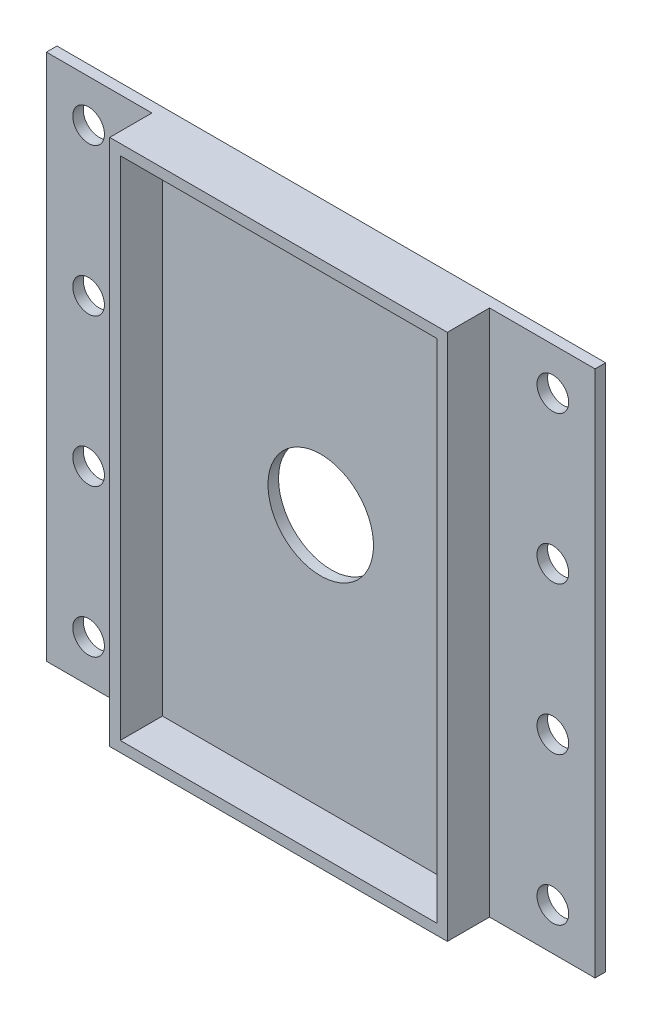
from build123d import *

# Parameters (mm, degrees)
ESQUISSE1_W             = 160
ESQUISSE1_H             = 250
ESQUISSE1_W_2           = 150
ESQUISSE1_H_2           = 240
BOSS_EXTRU_1_DEPTH      = 20
ESQUISSE2_W             = 260
ESQUISSE2_H             = 250
BOSS_EXTRU_2_DEPTH      = 5
ESQUISSE3_R             = 25
ENL_V_MAT_EXTRU_1_DEPTH = 5
ESQUISSE4_R             = 7.5
ENL_V_MAT_EXTRU_2_DEPTH = 10


with BuildPart() as part:
    # Esquisse1 → Boss.-Extru.1 (new body)
    with BuildSketch(Plane.XY):
        with Locations((-80, 125)):
            Rectangle(ESQUISSE1_W, ESQUISSE1_H)
        with Locations((-80, 125)):
            Rectangle(ESQUISSE1_W_2, ESQUISSE1_H_2, mode=Mode.SUBTRACT)
    extrude(amount=BOSS_EXTRU_1_DEPTH)

    # Esquisse2 → Boss.-Extru.2 (add)
    with BuildSketch(Plane(origin=(0, 0, 0), x_dir=(-1, 0, 0), z_dir=(0, 0, -1))):
        with Locations((80, 125)):
            Rectangle(ESQUISSE2_W, ESQUISSE2_H)
    extrude(amount=BOSS_EXTRU_2_DEPTH)

    # Esquisse3 → Enlèv. mat.-Extru.1 (cut)
    with BuildSketch(Plane(origin=(0, 0, -5), x_dir=(-1, 0, 0), z_dir=(0, 0, -1))):
        with Locations((80, 125)):
            Circle(ESQUISSE3_R)
    extrude(amount=-ENL_V_MAT_EXTRU_1_DEPTH, mode=Mode.SUBTRACT)

    # Esquisse4 → Enlèv. mat.-Extru.2 (cut)
    with BuildSketch(Plane.XY):
        with Locations((30, 230)):
            Circle(ESQUISSE4_R)
        with Locations((-190, 230)):
            Circle(ESQUISSE4_R)
        with Locations((-190, 160)):
            Circle(ESQUISSE4_R)
        with Locations((30, 160)):
            Circle(ESQUISSE4_R)
        with Locations((-190, 90)):
            Circle(ESQUISSE4_R)
        with Locations((30, 90)):
            Circle(ESQUISSE4_R)
        with Locations((-190, 20)):
            Circle(ESQUISSE4_R)
        with Locations((30, 20)):
            Circle(ESQUISSE4_R)
    extrude(amount=-ENL_V_MAT_EXTRU_2_DEPTH, mode=Mode.SUBTRACT)


solid = part.part
